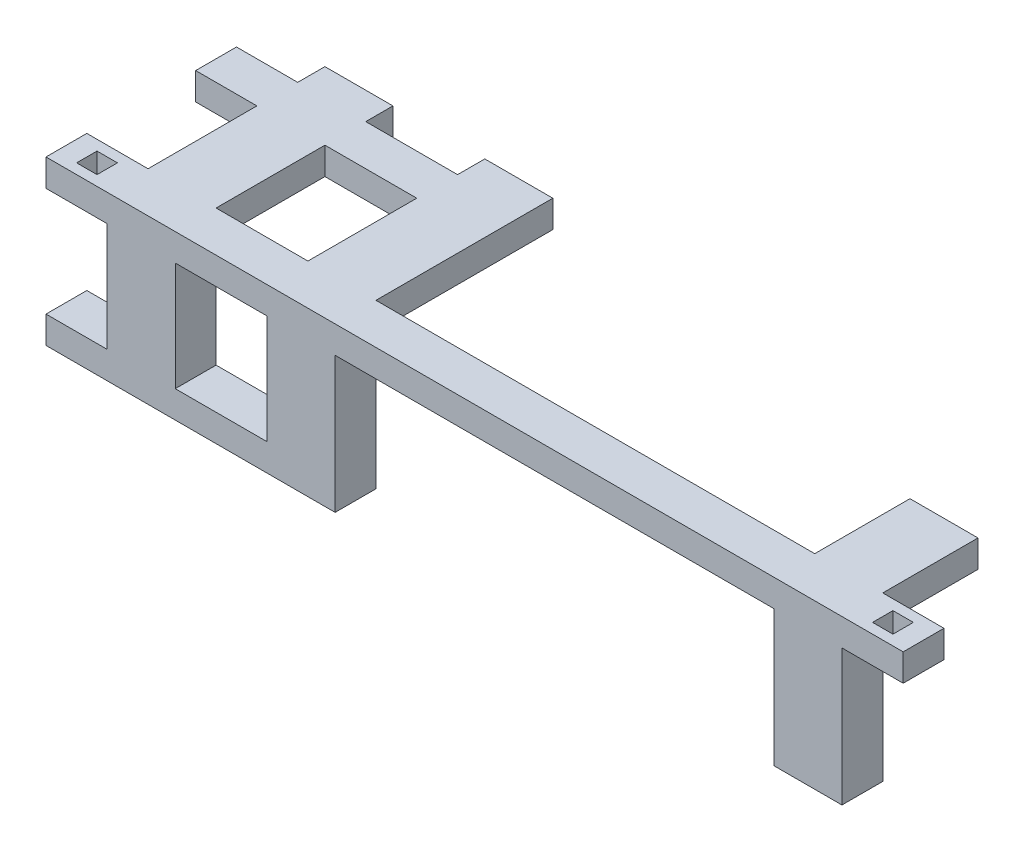
from build123d import *

# Parameters (mm, degrees)
SKETCH1_W           = 126
SKETCH1_H           = 6
BOSS_EXTRUDE1_DEPTH = 4
SKETCH2_W           = 3
SKETCH2_H           = 3
CUT_EXTRUDE1_DEPTH  = 4
SKETCH3_W           = 10
SKETCH3_H           = 6
BOSS_EXTRUDE2_DEPTH = 20
SKETCH4_W           = 10
SKETCH4_H           = 4
BOSS_EXTRUDE3_DEPTH = 26
SKETCH5_W           = 6
SKETCH5_H           = 4
BOSS_EXTRUDE4_DEPTH = 42.5
SKETCH6_W           = 10
SKETCH6_H           = 4
BOSS_EXTRUDE5_DEPTH = 14


with BuildPart() as part:
    # Sketch1 → Boss-Extrude1 (new body)
    with BuildSketch(Plane(origin=(0, 0, 0), x_dir=(1, 0, 0), z_dir=(0, 1, 0))):
        with Locations((63, 3)):
            Rectangle(SKETCH1_W, SKETCH1_H)
    extrude(amount=BOSS_EXTRUDE1_DEPTH)

    # Sketch2 → Cut-Extrude1 (cut)
    with BuildSketch(Plane(origin=(0, 4, 0), x_dir=(1, 0, 0), z_dir=(0, 1, 0))):
        with Locations((121.5, 3)):
            Rectangle(SKETCH2_W, SKETCH2_H)
        with Locations((4.5, 3)):
            Rectangle(SKETCH2_W, SKETCH2_H)
    extrude(amount=-CUT_EXTRUDE1_DEPTH, mode=Mode.SUBTRACT)

    # Sketch3 → Boss-Extrude2 (add)
    with BuildSketch(Plane(origin=(0, 0, 0), x_dir=(1, 0, 0), z_dir=(0, 1, 0))):
        with Locations((14, 3)):
            Rectangle(SKETCH3_W, SKETCH3_H)
        with Locations((112, 3)):
            Rectangle(SKETCH3_W, SKETCH3_H)
        with Locations((37.5, 3)):
            Rectangle(SKETCH3_W, SKETCH3_H)
    extrude(amount=-BOSS_EXTRUDE2_DEPTH)

    # Sketch4 → Boss-Extrude3 (add)
    with BuildSketch(Plane(origin=(0, 0, -6), x_dir=(-1, 0, 0), z_dir=(0, 0, -1))):
        with Locations((-14, 2)):
            Rectangle(SKETCH4_W, SKETCH4_H)
        with Locations((-37.5, 2)):
            Rectangle(SKETCH4_W, SKETCH4_H)
    extrude(amount=BOSS_EXTRUDE3_DEPTH)

    # Sketch5 → Boss-Extrude4 (add)
    with BuildSketch(Plane(origin=(42.5, 0, 0), x_dir=(0, 0, -1), z_dir=(1, 0, 0))):
        with Locations((25, 2)):
            Rectangle(SKETCH5_W, SKETCH5_H)
        with Locations((3, -18)):
            Rectangle(SKETCH5_W, SKETCH5_H)
    extrude(amount=-BOSS_EXTRUDE4_DEPTH)

    # Sketch6 → Boss-Extrude5 (add)
    with BuildSketch(Plane(origin=(0, 0, -6), x_dir=(-1, 0, 0), z_dir=(0, 0, -1))):
        with Locations((-112, 2)):
            Rectangle(SKETCH6_W, SKETCH6_H)
    extrude(amount=BOSS_EXTRUDE5_DEPTH)


solid = part.part
